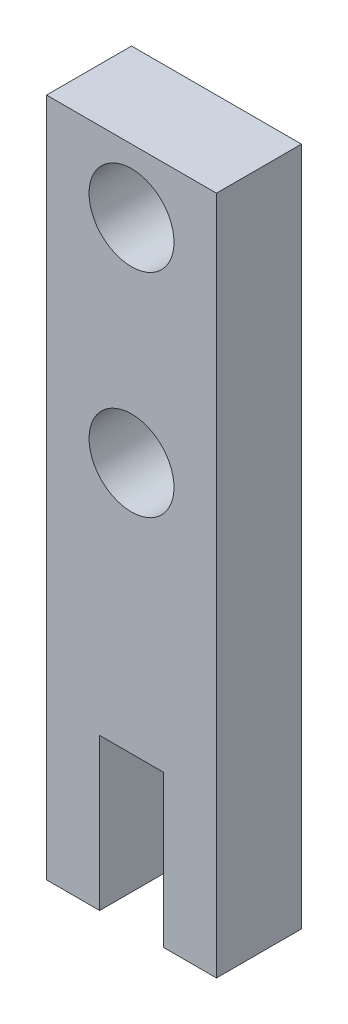
from build123d import *

# Parameters (mm, degrees)
SKETCH1_W               = 50.8
SKETCH1_H               = 203.2
BOSS_EXTRUDE1_DEPTH     = 25.4
SKETCH2_R               = 12.7
CUT_EXTRUDE1_DEPTH      = 1
CUT_EXTRUDE1_DEPTH_BACK = 26.4
SKETCH3_R               = 6.35
CUT_EXTRUDE2_DEPTH      = 26.4
SKETCH4_W               = 19.05
SKETCH4_H               = 45.349823228
CUT_EXTRUDE3_DEPTH      = 26.4


with BuildPart() as part:
    # Sketch1 → Boss-Extrude1 (new body)
    with BuildSketch(Plane.XY):
        with Locations((25.4, 101.6)):
            Rectangle(SKETCH1_W, SKETCH1_H)
    extrude(amount=BOSS_EXTRUDE1_DEPTH)

    # Sketch2 → Cut-Extrude1 (cut, two sides)
    with BuildSketch(Plane.XY.offset(25.4)) as cut_extrude1_sk:
        with Locations((25.4, 184.15)):
            Circle(SKETCH2_R)
        with Locations((25.4, 120.65)):
            Circle(SKETCH2_R)
    extrude(amount=CUT_EXTRUDE1_DEPTH, mode=Mode.SUBTRACT)
    extrude(cut_extrude1_sk.sketch, amount=-CUT_EXTRUDE1_DEPTH_BACK, mode=Mode.SUBTRACT)

    # Sketch3 → Cut-Extrude2 (cut, through all)
    with BuildSketch(Plane.XY.offset(25.4)):
        with Locations((25.4, 25.4)):
            Circle(SKETCH3_R)
    extrude(amount=-CUT_EXTRUDE2_DEPTH, mode=Mode.SUBTRACT)

    # Sketch4 → Cut-Extrude3 (cut, through all)
    with BuildSketch(Plane.XY.offset(25.4)):
        with Locations((25.4, 22.674911614)):
            Rectangle(SKETCH4_W, SKETCH4_H)
    extrude(amount=-CUT_EXTRUDE3_DEPTH, mode=Mode.SUBTRACT)


solid = part.part
